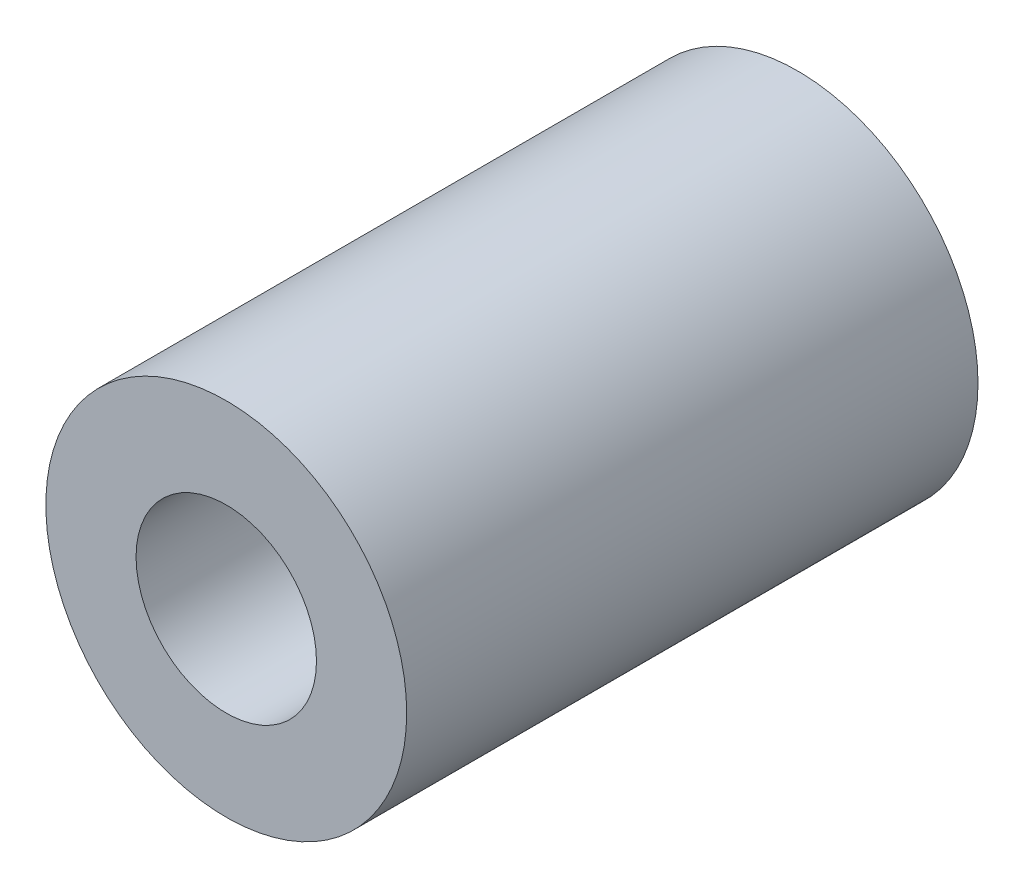
from build123d import *

# Parameters (mm, degrees)
SKETCH_1_R      = 6
SKETCH_1_R_2    = 3
EXTRUDE_1_DEPTH = 19


with BuildPart() as part:
    # ｽｹｯﾁ1 → ﾎﾞｽ - 押し出し1 (new body)
    with BuildSketch(Plane.XY):
        Circle(SKETCH_1_R)
        Circle(SKETCH_1_R_2, mode=Mode.SUBTRACT)
    extrude(amount=EXTRUDE_1_DEPTH)


solid = part.part
